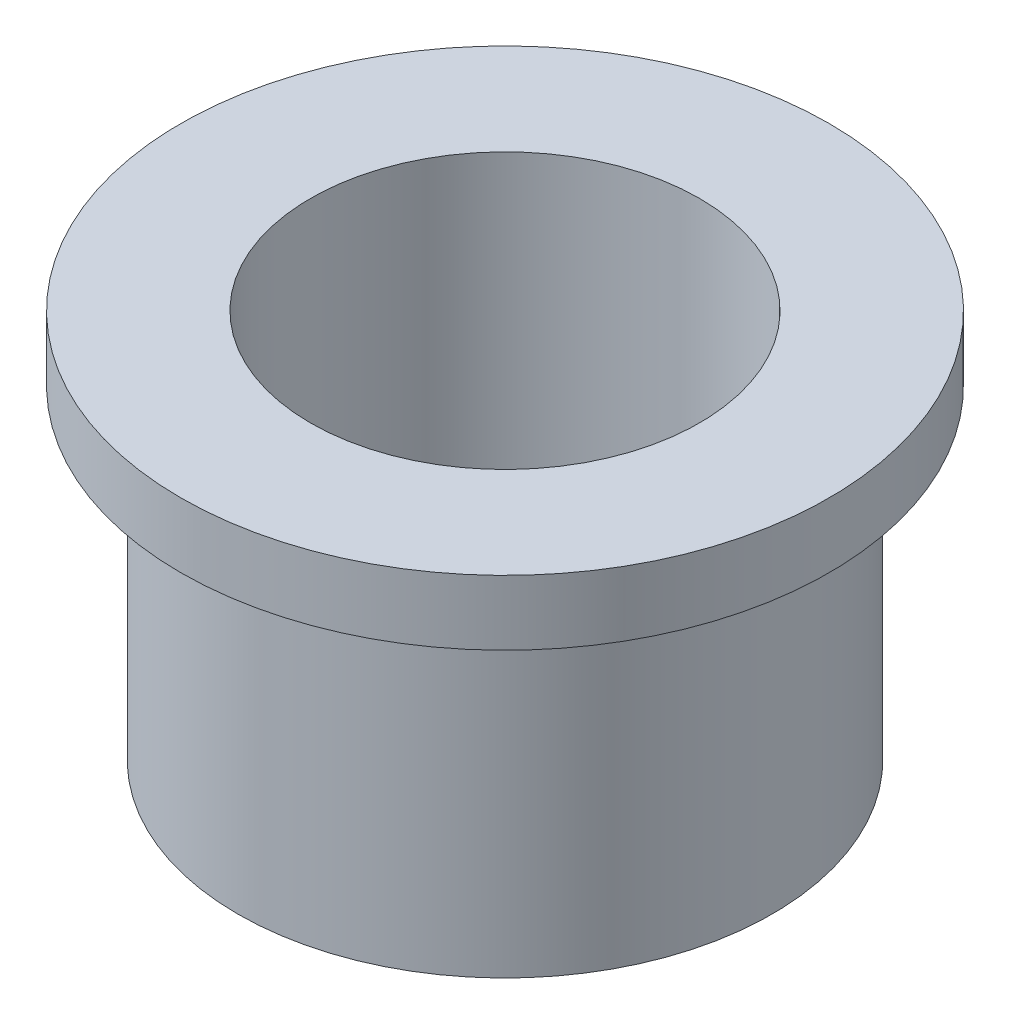
from build123d import *


with BuildPart() as part:
    # Sketch2 → Revolve1 (revolve)
    with BuildSketch(Plane(origin=(0, 0, 0), x_dir=(0, 0, -1), z_dir=(1, 0, 0))):
        Polygon((19.05, -38.1), (19.05, 0), (31.75, 0), (31.75, -6.35), (26.162, -6.35), (26.162, -38.1), align=None)
    revolve(axis=Axis((0, 0, 0), (0, -1, 0)))


solid = part.part
